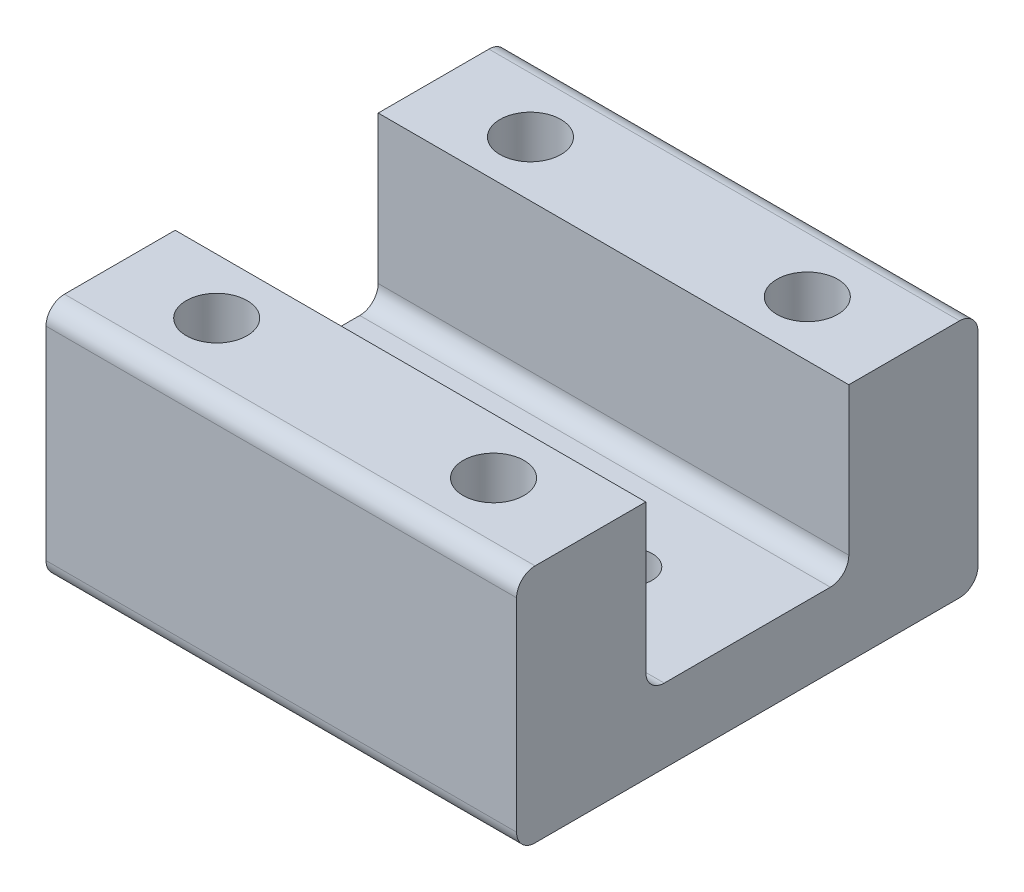
from build123d import *

# Parameters (mm, degrees)
SKETCH_1_W         = 25.5
SKETCH_1_H         = 25
EXTRUDE_1_DEPTH    = 4
SKETCH_6_W         = 25.5
SKETCH_6_H         = 7
EXTRUDE_2_DEPTH    = 9
HOLE_WIZARD_M3_1_D = 2.5
HOLE_WIZARD_M4_3_D = 3.3
FILLET_1_R         = 1


with BuildPart() as part:
    # 草图1 → 凸台-拉伸1 (new body)
    with BuildSketch(Plane(origin=(0, 0, 0), x_dir=(1, 0, 0), z_dir=(0, 1, 0))):
        Rectangle(SKETCH_1_W, SKETCH_1_H)
    extrude(amount=EXTRUDE_1_DEPTH)

    # 草图6 → 凸台-拉伸2 (add)
    with BuildSketch(Plane(origin=(0, 4, 0), x_dir=(1, 0, 0), z_dir=(0, 1, 0))):
        with Locations((0, 9)):
            Rectangle(SKETCH_6_W, SKETCH_6_H)
        with Locations((0, -9)):
            Rectangle(SKETCH_6_W, SKETCH_6_H)
    extrude(amount=EXTRUDE_2_DEPTH)

    # M3 螺纹孔1 (through all)
    with Locations(Plane(origin=(6.35, 0, 0), x_dir=(0, 0, -1), z_dir=(0, -1, 0))):
        with Locations((0, 0), (0, -12.7)):
            Hole(HOLE_WIZARD_M3_1_D / 2)

    # M4 螺纹孔3 (through all)
    with Locations(Plane(origin=(7.5, 0, 8.5), x_dir=(0, 0, -1), z_dir=(0, -1, 0))):
        with Locations((0, 0), (0, -15), (17, -15), (17, 0)):
            Hole(HOLE_WIZARD_M4_3_D / 2)

    # 圆角1
    fillet_1_edges = [part.edges().sort_by_distance(p)[0] for p in [
        (0, 4, -5.5),
        (0, 13, -12.5),
        (0, 4, 5.5),
        (0, 13, 12.5),
        (0, 0, 12.5),
        (0, 0, -12.5),
    ]]
    fillet(fillet_1_edges, radius=FILLET_1_R)


solid = part.part
